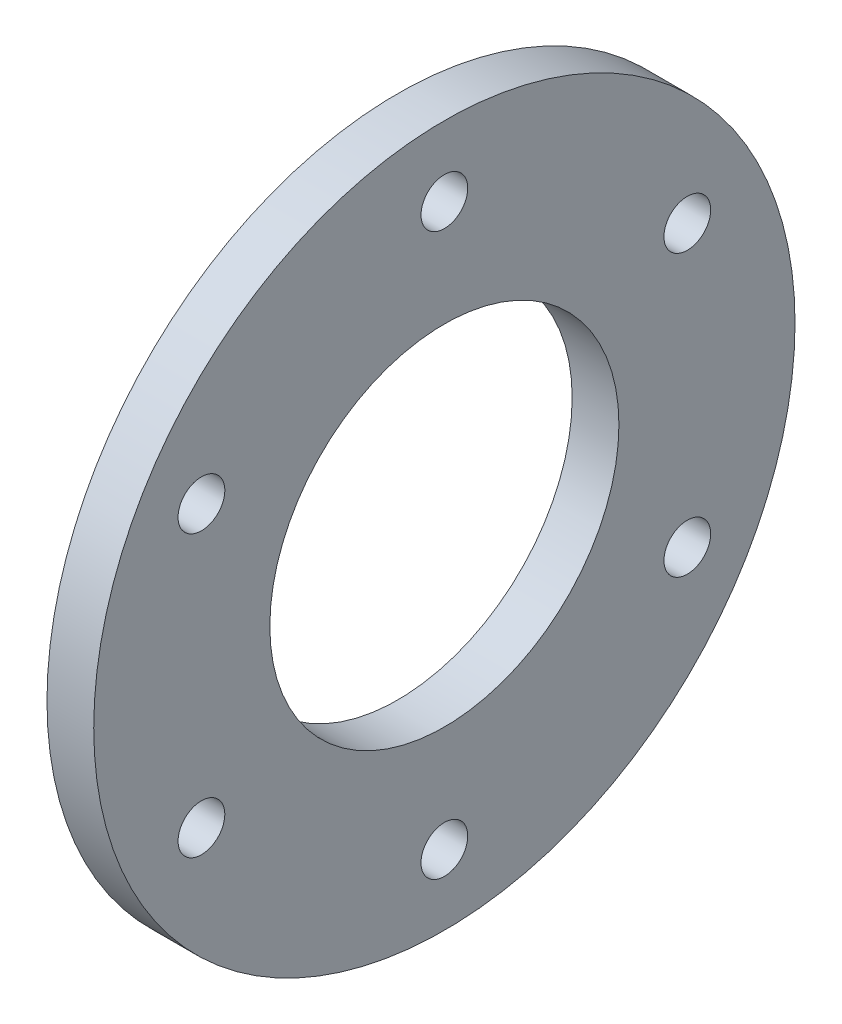
from build123d import *

# Parameters (mm, degrees)
SKETCH1_R          = 22.5
SKETCH1_R_2        = 11.2
EXTRUDE1_DEPTH     = 3
SKETCH2_R          = 1.5
CUT_EXTRUDE1_DEPTH = 4
CIRPATTERN1_COUNT  = 6


with BuildPart() as part:
    # Sketch1 → Extrude1 (new body)
    with BuildSketch(Plane(origin=(0, 0, 0), x_dir=(0, 0, -1), z_dir=(1, 0, 0))):
        Circle(SKETCH1_R)
        Circle(SKETCH1_R_2, mode=Mode.SUBTRACT)
    extrude(amount=EXTRUDE1_DEPTH)

    # Sketch2 → Cut-Extrude1 (cut, through all)
    with BuildSketch(Plane(origin=(3, 0, 0), x_dir=(0, 0, -1), z_dir=(1, 0, 0))):
        with Locations((0, 18)):
            Circle(SKETCH2_R)
    cut_extrude1 = extrude(amount=-CUT_EXTRUDE1_DEPTH, mode=Mode.SUBTRACT)

    # CirPattern1: Cut-Extrude1 ×6 about axis
    cirpattern1_axis = Axis((0, 0, 0), (1, 0, 0))
    for i in range(1, CIRPATTERN1_COUNT):
        add(cut_extrude1.rotate(cirpattern1_axis, i * 360 / CIRPATTERN1_COUNT), mode=Mode.SUBTRACT)


solid = part.part
